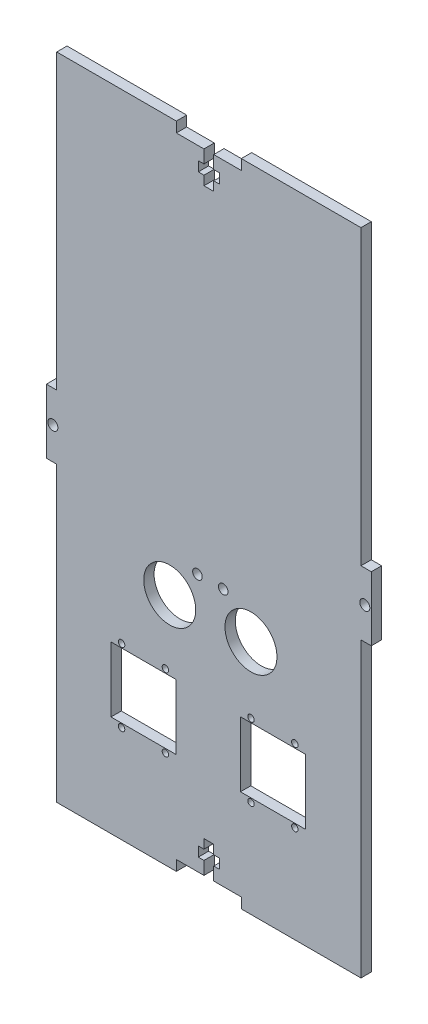
from build123d import *

# Parameters (mm, degrees)
SKETCH1_W           = 100
SKETCH1_H           = 200
BOSS_EXTRUDE2_DEPTH = 3.18
SKETCH2_R           = 1.55
SKETCH2_W           = 3.18
SKETCH2_H           = 90.125
CUT_EXTRUDE1_DEPTH  = 4.18
SKETCH4_R           = 1
CUT_EXTRUDE15_DEPTH = 10
SKETCH5_R           = 8
CUT_EXTRUDE16_DEPTH = 4.18
SKETCH6_R           = 1.47
CUT_EXTRUDE17_DEPTH = 4.18
SKETCH7_W           = 20
SKETCH7_H           = 20
CUT_EXTRUDE18_DEPTH = 4.18


with BuildPart() as part:
    # Sketch1 → Boss-Extrude2 (new body)
    with BuildSketch(Plane.XY):
        Rectangle(SKETCH1_W, SKETCH1_H)
    extrude(amount=BOSS_EXTRUDE2_DEPTH)

    # Sketch2 → Cut-Extrude1 (cut, through all)
    with BuildSketch(Plane.XY.offset(3.18)):
        with Locations((-48, 0)):
            Circle(SKETCH2_R)
        Polygon((-10, 100), (-10, 96.82), (-1.5, 96.82), (-1.5, 92.82), (-3.25, 92.82), (-3.25, 89.82), (-1.5, 89.82), (-1.5, 87), (1.5, 87), (1.5, 89.82), (3.25, 89.82), (3.25, 92.82), (1.5, 92.82), (1.5, 96.82), (10, 96.82), (10, 100), align=None)
        with Locations((-48.41, 54.9375)):
            Rectangle(SKETCH2_W, SKETCH2_H)
        with Locations((-48.41, -54.9375)):
            Rectangle(SKETCH2_W, SKETCH2_H)
    cut_extrude1 = extrude(amount=-CUT_EXTRUDE1_DEPTH, mode=Mode.SUBTRACT)

    # Mirror1: Cut-Extrude1 across plane
    add(cut_extrude1.mirror(Plane.ZX), mode=Mode.SUBTRACT)

    # Mirror3: Cut-Extrude1 across plane
    add(cut_extrude1.mirror(Plane(origin=(0, 0, 0), x_dir=(0, 0, 1), z_dir=(1, 0, 0))), mode=Mode.SUBTRACT)

    # Sketch4 → Cut-Extrude15 (cut)
    with BuildSketch(Plane(origin=(0, 0, 0), x_dir=(-1, 0, 0), z_dir=(0, 0, -1))):
        with Locations((13.361708712, -70.119061845)):
            Circle(SKETCH4_R)
        with Locations((26.861708712, -70.119061845)):
            Circle(SKETCH4_R)
        with Locations((26.861708712, -47.659061845)):
            Circle(SKETCH4_R)
        with Locations((13.361708712, -47.659061845)):
            Circle(SKETCH4_R)
        with Locations((-12.978894748, -47.682446814)):
            Circle(SKETCH4_R)
        with Locations((-26.478894748, -47.682446814)):
            Circle(SKETCH4_R)
        with Locations((-26.478894748, -70.142446814)):
            Circle(SKETCH4_R)
        with Locations((-12.978894748, -70.142446814)):
            Circle(SKETCH4_R)
    extrude(amount=-CUT_EXTRUDE15_DEPTH, mode=Mode.SUBTRACT)

    # Sketch5 → Cut-Extrude16 (cut, through all)
    with BuildSketch(Plane(origin=(0, 0, 0), x_dir=(-1, 0, 0), z_dir=(0, 0, -1))):
        with Locations((12.031607873, -27.34212165)):
            Circle(SKETCH5_R)
        with Locations((-12.968392127, -27.34212165)):
            Circle(SKETCH5_R)
    extrude(amount=-CUT_EXTRUDE16_DEPTH, mode=Mode.SUBTRACT)

    # Sketch6 → Cut-Extrude17 (cut, through all)
    with BuildSketch(Plane(origin=(0, 0, 0), x_dir=(-1, 0, 0), z_dir=(0, 0, -1))):
        with Locations((3.495113066, -17.537619805)):
            Circle(SKETCH6_R)
        with Locations((-4.43189732, -17.537619805)):
            Circle(SKETCH6_R)
    extrude(amount=-CUT_EXTRUDE17_DEPTH, mode=Mode.SUBTRACT)

    # Sketch7 → Cut-Extrude18 (cut, through all)
    with BuildSketch(Plane(origin=(0, 0, 0), x_dir=(-1, 0, 0), z_dir=(0, 0, -1))):
        with Locations((20.111708712, -58.889061845)):
            Rectangle(SKETCH7_W, SKETCH7_H)
        with Locations((-19.728894748, -58.912446814)):
            Rectangle(SKETCH7_W, SKETCH7_H)
    extrude(amount=-CUT_EXTRUDE18_DEPTH, mode=Mode.SUBTRACT)


solid = part.part
